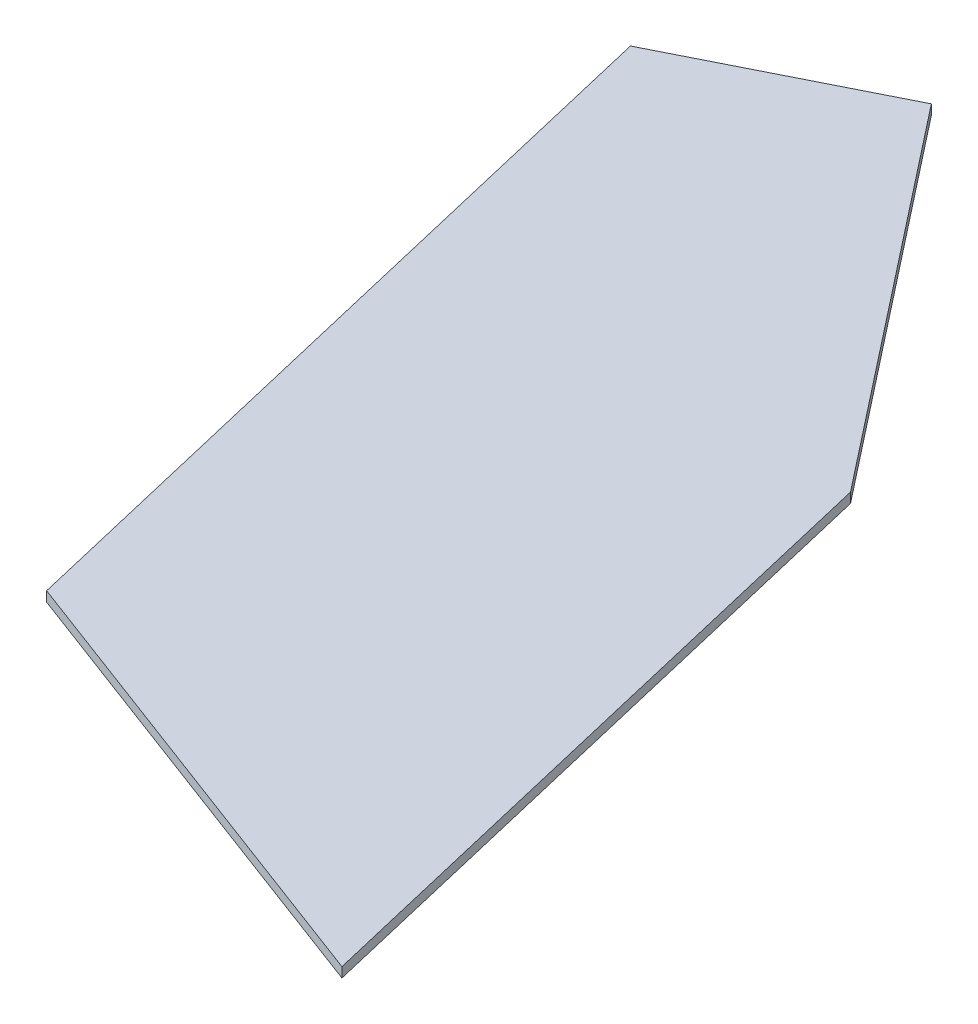
from build123d import *

# Parameters (mm, degrees)
BOSS_EXTRU_1_DEPTH = 2


with BuildPart() as part:
    # Esquisse1 → Boss.-Extru.1 (new body)
    with BuildSketch(Plane(origin=(0, 0, 0), x_dir=(1, 0, 0), z_dir=(0, 1, 0))):
        Polygon((-36.507053773, 154.99641939), (0, 0), (96.02407972, -36.09385835), (64.221794297, 98.927729526), (4.194954591, 175.363159542), align=None)
    extrude(amount=BOSS_EXTRU_1_DEPTH)


solid = part.part
